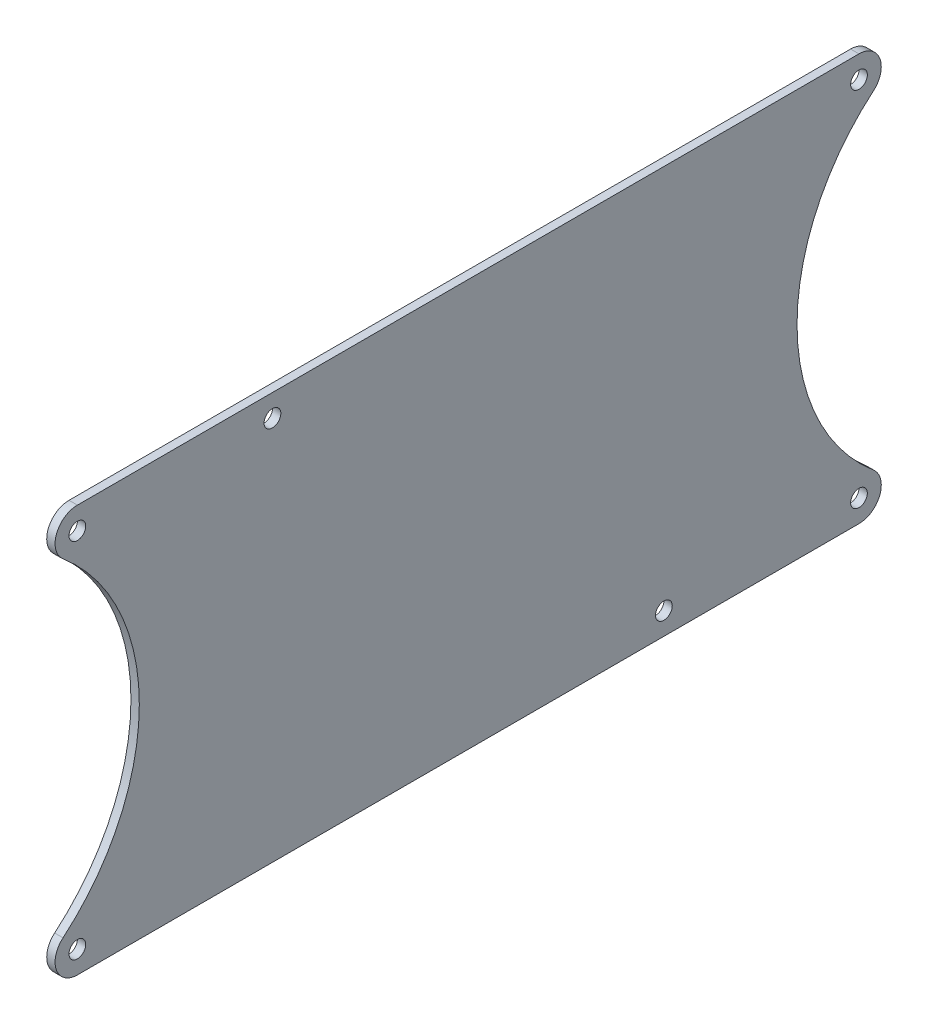
from build123d import *

# Parameters (mm, degrees)
BOSS_EXTRUDE1_DEPTH       = 1.5
FILLET1_R                 = 4
F_3_0MM_DOWEL_HOLE2_D     = 3
F_3_0MM_DOWEL_HOLE2_DEPTH = 17.29
F_3_0MM_DOWEL_HOLE2_TIP   = 0.901290929


with BuildPart() as part:
    # Sketch1 → Boss-Extrude1 (new body)
    with BuildSketch(Plane(origin=(0, 0, 0), x_dir=(0, 0, -1), z_dir=(1, 0, 0))):
        with BuildLine():
            Line((164.111754286, 40.215722327), (-6.393348286, 40.215722327))
            ThreePointArc((-6.393348286, 40.215722327), (12.614416769, 26.195971709), (19.859203, 3.715722327))
            ThreePointArc((19.859203, 3.715722327), (12.614416769, -18.764527055), (-6.393348286, -32.784277673))
            Line((-6.393348286, -32.784277673), (164.111754286, -32.784277673))
            ThreePointArc((164.111754286, -32.784277673), (137.859203, 3.715722327), (164.111754286, 40.215722327))
        make_face()
    extrude(amount=BOSS_EXTRUDE1_DEPTH)

    # Fillet1
    fillet1_edges = [part.edges().sort_by_distance(p)[0] for p in [
        (0.75, -32.784277673, -164.111754286),
        (0.75, -32.784277673, 6.393348286),
        (0.75, 40.215722327, 6.393348286),
        (0.75, 40.215722327, -164.111754286),
    ]]
    fillet(fillet1_edges, radius=FILLET1_R)

    # Ø3.0mm Dowel Hole2
    with Locations(Plane(origin=(1.5, 0, 0), x_dir=(0, 0, -1), z_dir=(1, 0, 0))):
        with Locations((8.745330875, 36.215722327), (148.973075124, 36.215722327), (148.973075124, -28.784277673), (8.745330875, -28.784277673), (43.745330875, 36.215722327), (113.973075124, -28.784277673)):
            Hole(F_3_0MM_DOWEL_HOLE2_D / 2, depth=F_3_0MM_DOWEL_HOLE2_DEPTH)
            with Locations((0, 0, -(F_3_0MM_DOWEL_HOLE2_DEPTH + F_3_0MM_DOWEL_HOLE2_TIP / 2))):  # 118° drill point
                Cone(0, F_3_0MM_DOWEL_HOLE2_D / 2, F_3_0MM_DOWEL_HOLE2_TIP, mode=Mode.SUBTRACT)


solid = part.part
